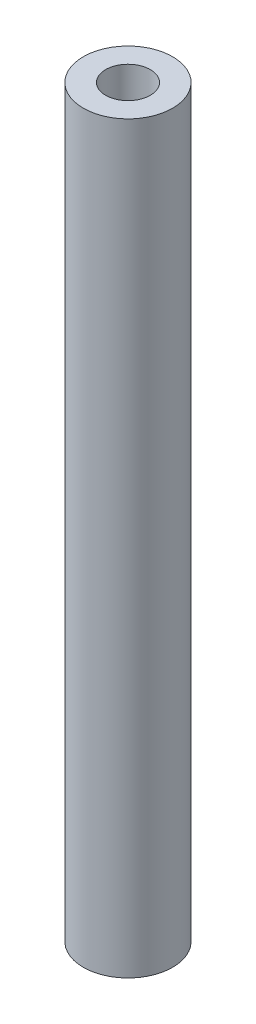
from build123d import *

# Parameters (mm, degrees)
SKETCH1_R           = 6
SKETCH1_R_2         = 1.5
BOSS_EXTRUDE1_DEPTH = 100
SKETCH2_R           = 3
CUT_EXTRUDE1_DEPTH  = 5
SKETCH3_R           = 3
CUT_EXTRUDE2_DEPTH  = 5


with BuildPart() as part:
    # Sketch1 → Boss-Extrude1 (new body)
    with BuildSketch(Plane(origin=(0, 0, 0), x_dir=(1, 0, 0), z_dir=(0, 1, 0))):
        Circle(SKETCH1_R)
        Circle(SKETCH1_R_2, mode=Mode.SUBTRACT)
    extrude(amount=BOSS_EXTRUDE1_DEPTH)

    # Sketch2 → Cut-Extrude1 (cut)
    with BuildSketch(Plane(origin=(0, 100, 0), x_dir=(1, 0, 0), z_dir=(0, 1, 0))):
        Circle(SKETCH2_R)
    extrude(amount=-CUT_EXTRUDE1_DEPTH, mode=Mode.SUBTRACT)

    # Sketch3 → Cut-Extrude2 (cut)
    with BuildSketch(Plane.XZ):
        Circle(SKETCH3_R)
    extrude(amount=-CUT_EXTRUDE2_DEPTH, mode=Mode.SUBTRACT)


solid = part.part
